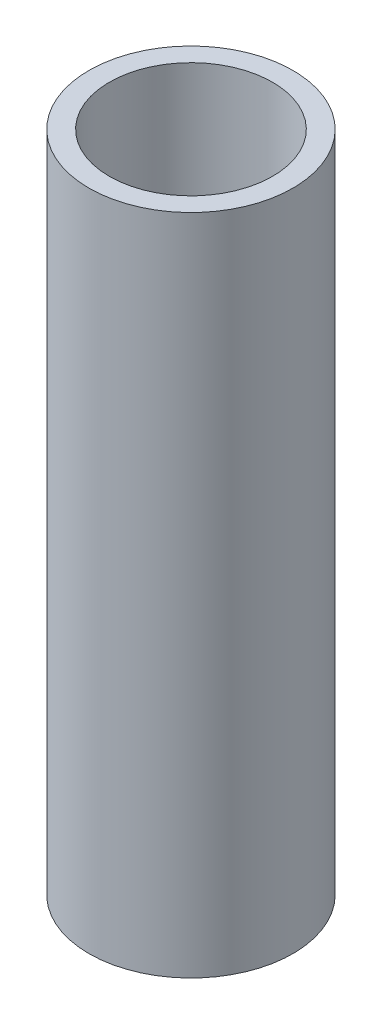
from build123d import *

# Parameters (mm, degrees)
SKETCH1_R           = 31.75
SKETCH1_R_2         = 25.4
BOSS_EXTRUDE1_DEPTH = 206.375


with BuildPart() as part:
    # Sketch1 → Boss-Extrude1 (new body)
    with BuildSketch(Plane(origin=(0, 0, 0), x_dir=(1, 0, 0), z_dir=(0, 1, 0))):
        Circle(SKETCH1_R)
        Circle(SKETCH1_R_2, mode=Mode.SUBTRACT)
    extrude(amount=BOSS_EXTRUDE1_DEPTH)


solid = part.part
